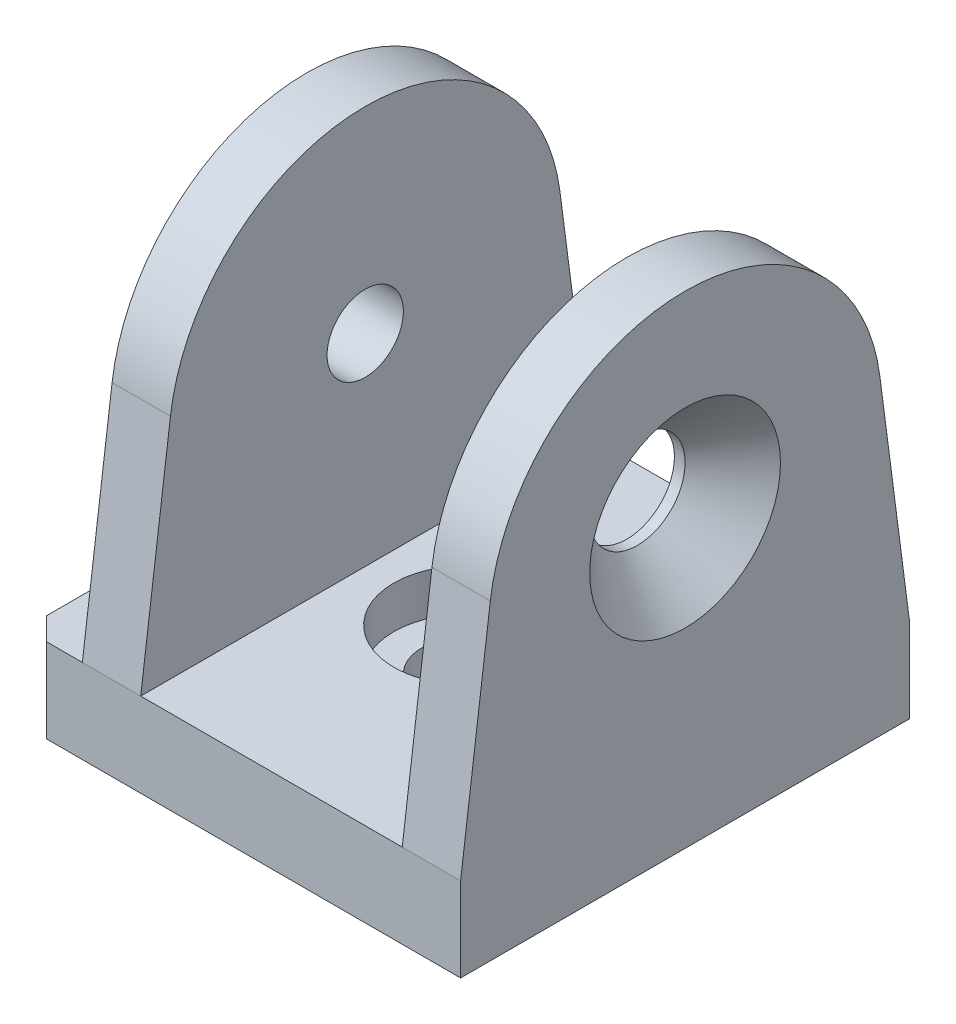
from build123d import *

# Parameters (mm, degrees)
SKETCH_1_W               = 38.9
SKETCH_1_H               = 40
EXTRUDE_1_DEPTH          = 7.5
EXTRUDE_2_DEPTH          = 33.7
SKETCH_4_W               = 23.3
SKETCH_4_H               = 35.5
CUT_EXTRUDE_1_DEPTH      = 21
CUT_EXTRUDE_1_DEPTH_BACK = 21
CHAMFER_1_SIZE           = 2
HOLE_WIZARD_M81_2_D      = 6.8
HOLE_WIZARD_M81_2_DEPTH  = 5.2


with BuildPart() as part:
    # Эскиз1 → Бобышка-Вытянуть1 (new body)
    with BuildSketch(Plane(origin=(0, 0, 0), x_dir=(1, 0, 0), z_dir=(0, 1, 0))):
        Rectangle(SKETCH_1_W, SKETCH_1_H)
    extrude(amount=EXTRUDE_1_DEPTH)

    # Эскиз2 → Вырез-Повернуть1 (revolve, cut)
    with BuildSketch(Plane.XY):
        Polygon((-4, 0), (-4, 3.75), (-6.5, 3.75), (-6.5, 7.5), (0, 7.5), (0, 0), align=None)
    revolve(axis=Axis((0, 7.5, 0), (0, -1, 0)), mode=Mode.SUBTRACT)

    # Эскиз3 → Бобышка-Вытянуть2 (add)
    with BuildSketch(Plane(origin=(19.45, 0, 0), x_dir=(0, 0, -1), z_dir=(1, 0, 0))):
        with BuildLine():
            Line((-20, 7.5), (-17.35257463, 27.766749589))
            ThreePointArc((-17.35257463, 27.766749589), (0, 43), (17.35257463, 27.766749589))
            Line((17.35257463, 27.766749589), (20, 7.5))
            Line((20, 7.5), (-20, 7.5))
        make_face()
    extrude(amount=-EXTRUDE_2_DEPTH)

    # Эскиз4 → Вырез-Вытянуть1 (cut, two sides)
    with BuildSketch(Plane.XY) as cut_extrude_1_sk:
        with Locations((2.6, 25.25)):
            Rectangle(SKETCH_4_W, SKETCH_4_H)
    extrude(amount=CUT_EXTRUDE_1_DEPTH, mode=Mode.SUBTRACT)
    extrude(cut_extrude_1_sk.sketch, amount=-CUT_EXTRUDE_1_DEPTH_BACK, mode=Mode.SUBTRACT)

    # Фаска1
    chamfer_1_edges = [part.edges().sort_by_distance(p)[0] for p in [
        (-19.45, 3.75, -20),
        (-19.45, 3.75, 20),
    ]]
    chamfer(chamfer_1_edges, length=CHAMFER_1_SIZE)

    # Эскиз10 → Hole Wizard M81 (revolve, cut)
    with BuildSketch(Plane(origin=(19.45, 25.5, 0), x_dir=(0, 0, -1), z_dir=(0, 1, 0))):
        Polygon((0, 0), (0, 5.2), (4.25, 5.2), (4.25, 4.25), (8.5, 0), align=None)
    revolve(axis=Axis((25.8, 25.5, 0), (-1, 0, 0)), mode=Mode.SUBTRACT)

    # Hole Wizard M81 2
    with Locations(Plane.ZY.offset(14.25)):
        with Locations((0, 25.5)):
            Hole(HOLE_WIZARD_M81_2_D / 2, depth=HOLE_WIZARD_M81_2_DEPTH)


solid = part.part
